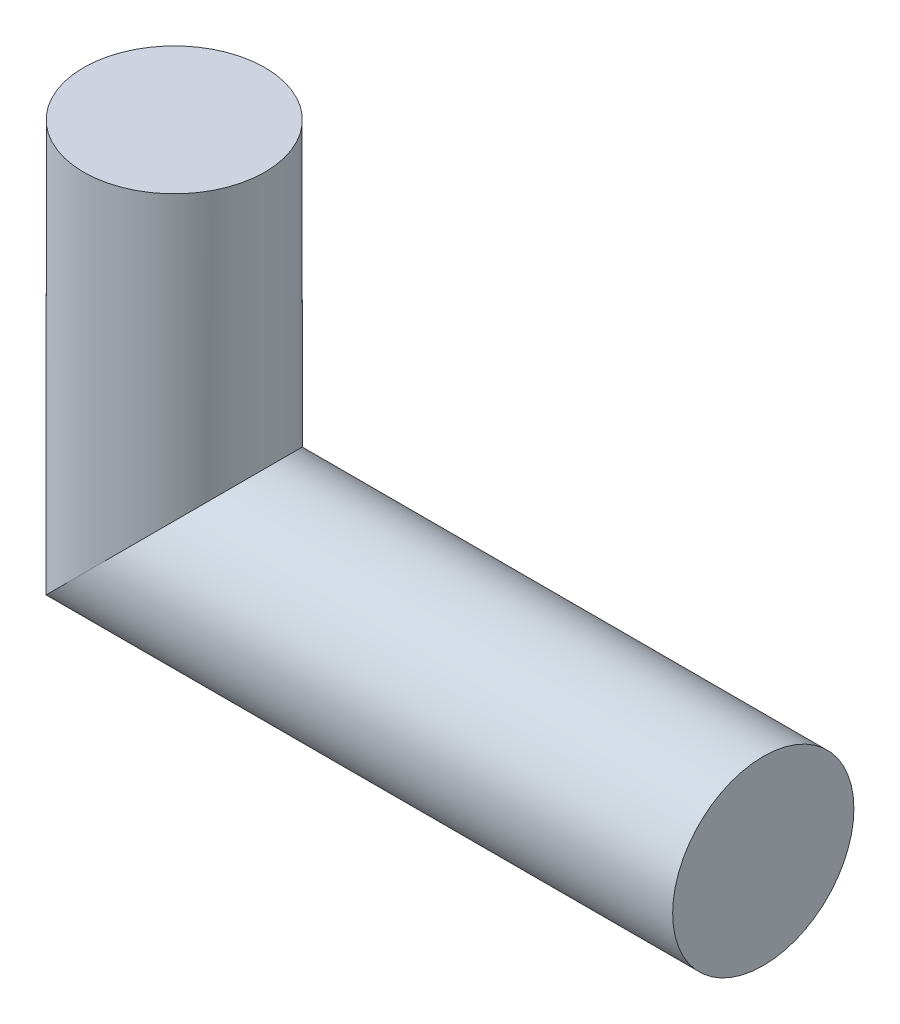
from build123d import *

# Parameters (mm, degrees)
SKETCH1_R = 6


with BuildPart() as part:
    # Sweep1: sweep along a path in Sketch2
    with BuildLine(Plane.XY) as sweep1_path:
        Line((0, 0), (-39, 0))
        Line((-39, 0), (-39, 23))
    # Sketch1 → Sweep1 (sweep)
    with BuildSketch(Plane(origin=(0, 0, 0), x_dir=(0, 0, -1), z_dir=(1, 0, 0))):
        Circle(SKETCH1_R)
    sweep(path=sweep1_path.line, transition=Transition.RIGHT)


solid = part.part
